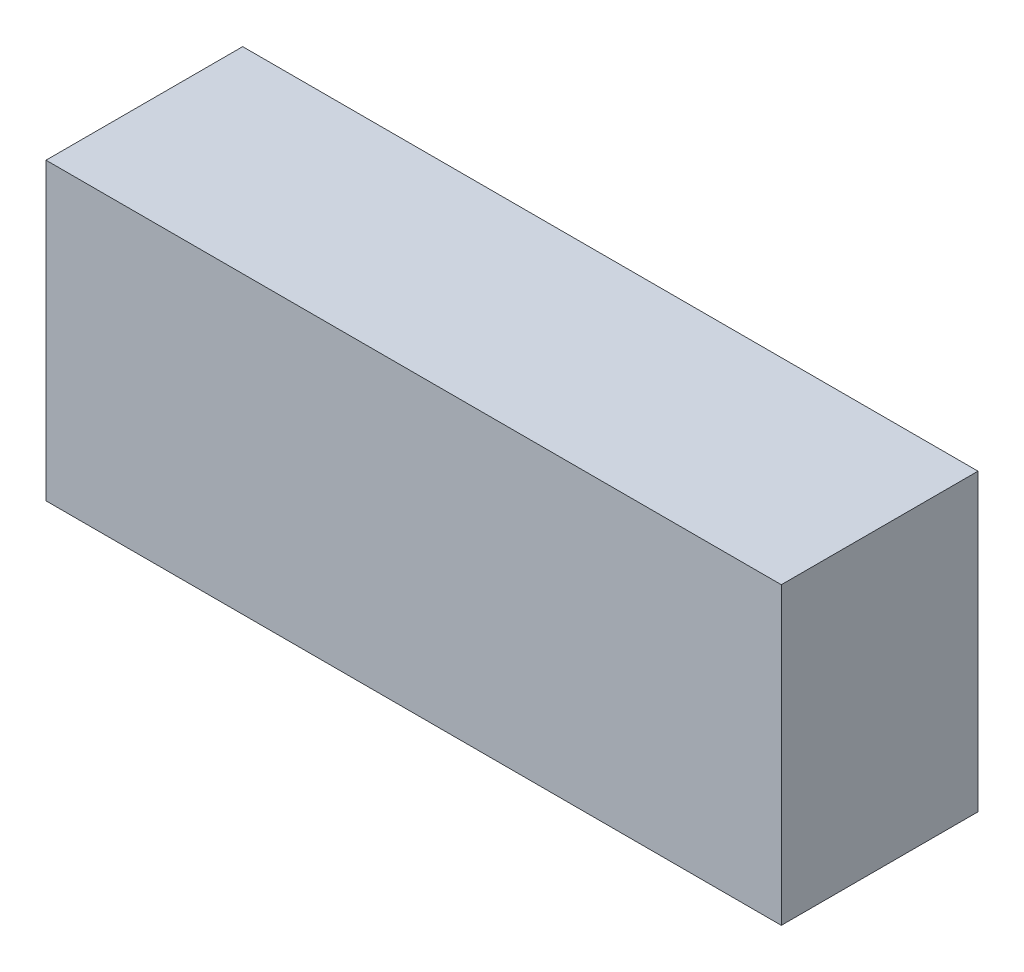
from build123d import *

# Parameters (mm, degrees)
SKETCH1_W      = 37.385703918
SKETCH1_H      = 15
EXTRUDE1_DEPTH = 10


with BuildPart() as part:
    # Sketch1 → Extrude1 (new body)
    with BuildSketch(Plane.XY):
        Rectangle(SKETCH1_W, SKETCH1_H)
    extrude(amount=EXTRUDE1_DEPTH)


solid = part.part
